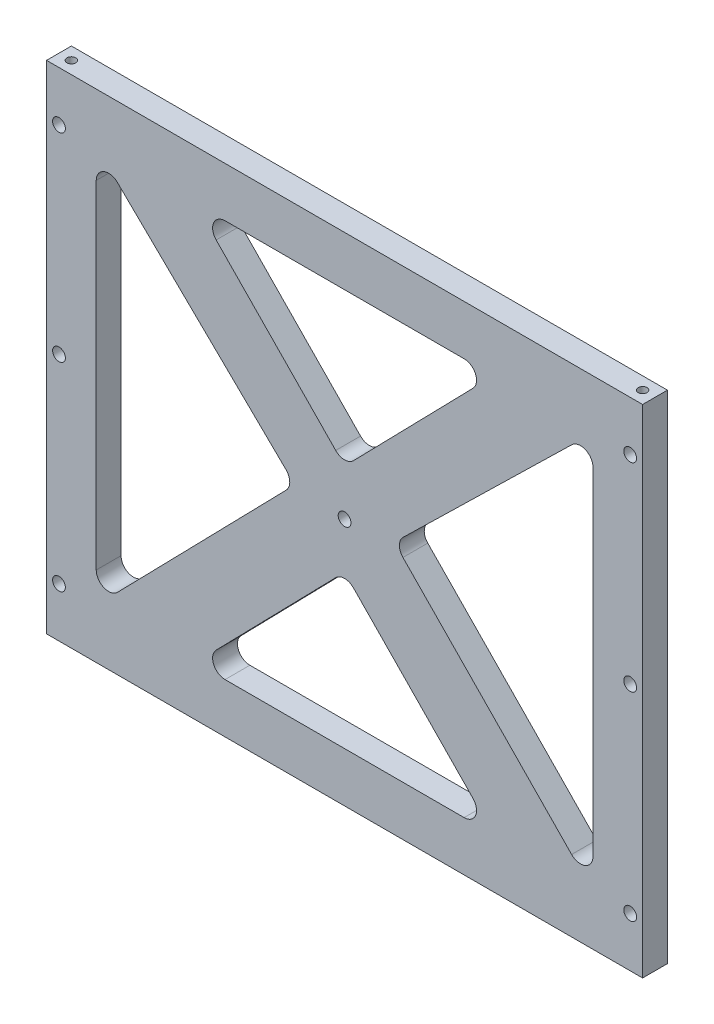
from build123d import *

# Parameters (mm, degrees)
SKETCH1_W                                      = 152.4
SKETCH1_H                                      = 127
BOSS_EXTRUDE1_DEPTH                            = 6.35
CUT_EXTRUDE1_DEPTH                             = 7.35
F_4_40_TAPPED_HOLE1_D                          = 2.2606
F_4_40_TAPPED_HOLE1_DEPTH                      = 7.5946
F_4_40_TAPPED_HOLE1_TIP                        = 0.679152758
CBORE_FOR_4_SOCKET_HEAD_CAP_SCREW1_D           = 3.2639
CBORE_FOR_4_SOCKET_HEAD_CAP_SCREW1_DEPTH       = 7.5946
CBORE_FOR_4_SOCKET_HEAD_CAP_SCREW1_CBORE_D     = 5.55752
CBORE_FOR_4_SOCKET_HEAD_CAP_SCREW1_CBORE_DEPTH = 2.8448
CBORE_FOR_4_SOCKET_HEAD_CAP_SCREW1_TIP         = 0.980574487
CBORE_FOR_4_SOCKET_HEAD_CAP_SCREW2_D           = 3.2639
CBORE_FOR_4_SOCKET_HEAD_CAP_SCREW2_DEPTH       = 7.5946
CBORE_FOR_4_SOCKET_HEAD_CAP_SCREW2_CBORE_D     = 5.55752
CBORE_FOR_4_SOCKET_HEAD_CAP_SCREW2_CBORE_DEPTH = 2.8448
CBORE_FOR_4_SOCKET_HEAD_CAP_SCREW2_TIP         = 0.980574487
F_4_40_TAPPED_HOLE2_D                          = 2.2606
F_4_40_TAPPED_HOLE2_DEPTH                      = 7.5946
F_4_40_TAPPED_HOLE2_TIP                        = 0.679152758
FILLET1_R                                      = 3.175


with BuildPart() as part:
    # Sketch1 → Boss-Extrude1 (new body)
    with BuildSketch(Plane.XY):
        Rectangle(SKETCH1_W, SKETCH1_H)
    extrude(amount=BOSS_EXTRUDE1_DEPTH)

    # Sketch2 → Cut-Extrude1 (cut, through all)
    with BuildSketch(Plane.XY.offset(6.35)):
        Polygon((63.5, 50.8), (63.5, -50.8), (12.7, 1.254738493), align=None)
        Polygon((-63.5, -50.8), (-12.7, 1.254738493), (-63.5, 50.8), align=None)
        Polygon((38.1, -50.8), (-38.1, -50.8), (0, -11.758946131), align=None)
        Polygon((-38.1, 50.8), (0, 11.758946131), (38.1, 50.8), align=None)
    extrude(amount=-CUT_EXTRUDE1_DEPTH, mode=Mode.SUBTRACT)

    # #4-40 Tapped Hole1
    with Locations(Plane(origin=(0, -63.5, 0), x_dir=(-1, 0, 0), z_dir=(0, -1, 0))):
        with Locations((-73.025, -3.175), (73.025, -3.175)):
            Hole(F_4_40_TAPPED_HOLE1_D / 2, depth=F_4_40_TAPPED_HOLE1_DEPTH)
            with Locations((0, 0, -(F_4_40_TAPPED_HOLE1_DEPTH + F_4_40_TAPPED_HOLE1_TIP / 2))):  # 118° drill point
                Cone(0, F_4_40_TAPPED_HOLE1_D / 2, F_4_40_TAPPED_HOLE1_TIP, mode=Mode.SUBTRACT)

    # CBORE for #4 Socket Head Cap Screw1
    with Locations(Plane(origin=(0, 0, 0), x_dir=(-1, 0, 0), z_dir=(0, 0, -1))):
        with Locations((73.025, 0), (73.025, 50.8), (-73.025, 50.8), (-73.025, 0), (-73.025, -50.8), (73.025, -50.8)):
            CounterBoreHole(CBORE_FOR_4_SOCKET_HEAD_CAP_SCREW1_D / 2, CBORE_FOR_4_SOCKET_HEAD_CAP_SCREW1_CBORE_D / 2, CBORE_FOR_4_SOCKET_HEAD_CAP_SCREW1_CBORE_DEPTH, depth=CBORE_FOR_4_SOCKET_HEAD_CAP_SCREW1_DEPTH)
            with Locations((0, 0, -(CBORE_FOR_4_SOCKET_HEAD_CAP_SCREW1_DEPTH + CBORE_FOR_4_SOCKET_HEAD_CAP_SCREW1_TIP / 2))):  # 118° drill point
                Cone(0, CBORE_FOR_4_SOCKET_HEAD_CAP_SCREW1_D / 2, CBORE_FOR_4_SOCKET_HEAD_CAP_SCREW1_TIP, mode=Mode.SUBTRACT)

    # CBORE for #4 Socket Head Cap Screw2
    with Locations(Plane(origin=(0, 0, 0), x_dir=(-1, 0, 0), z_dir=(0, 0, -1))):
        with Locations((0, 0)):
            CounterBoreHole(CBORE_FOR_4_SOCKET_HEAD_CAP_SCREW2_D / 2, CBORE_FOR_4_SOCKET_HEAD_CAP_SCREW2_CBORE_D / 2, CBORE_FOR_4_SOCKET_HEAD_CAP_SCREW2_CBORE_DEPTH, depth=CBORE_FOR_4_SOCKET_HEAD_CAP_SCREW2_DEPTH)
            with Locations((0, 0, -(CBORE_FOR_4_SOCKET_HEAD_CAP_SCREW2_DEPTH + CBORE_FOR_4_SOCKET_HEAD_CAP_SCREW2_TIP / 2))):  # 118° drill point
                Cone(0, CBORE_FOR_4_SOCKET_HEAD_CAP_SCREW2_D / 2, CBORE_FOR_4_SOCKET_HEAD_CAP_SCREW2_TIP, mode=Mode.SUBTRACT)

    # #4-40 Tapped Hole2
    with Locations(Plane(origin=(0, 63.5, 0), x_dir=(1, 0, 0), z_dir=(0, 1, 0))):
        with Locations((-73.025, -3.175), (73.025, -3.175)):
            Hole(F_4_40_TAPPED_HOLE2_D / 2, depth=F_4_40_TAPPED_HOLE2_DEPTH)
            with Locations((0, 0, -(F_4_40_TAPPED_HOLE2_DEPTH + F_4_40_TAPPED_HOLE2_TIP / 2))):  # 118° drill point
                Cone(0, F_4_40_TAPPED_HOLE2_D / 2, F_4_40_TAPPED_HOLE2_TIP, mode=Mode.SUBTRACT)

    # Fillet1
    fillet1_edges = [part.edges().sort_by_distance(p)[0] for p in [
        (0, -11.758946131, 3.175),
        (38.1, -50.8, 3.175),
        (-38.1, -50.8, 3.175),
        (-63.5, -50.8, 3.175),
        (-63.5, 50.8, 3.175),
        (-12.7, 1.254738493, 3.175),
        (-38.1, 50.8, 3.175),
        (38.1, 50.8, 3.175),
        (0, 11.758946131, 3.175),
        (12.7, 1.254738493, 3.175),
        (63.5, 50.8, 3.175),
        (63.5, -50.8, 3.175),
    ]]
    fillet(fillet1_edges, radius=FILLET1_R)


solid = part.part
